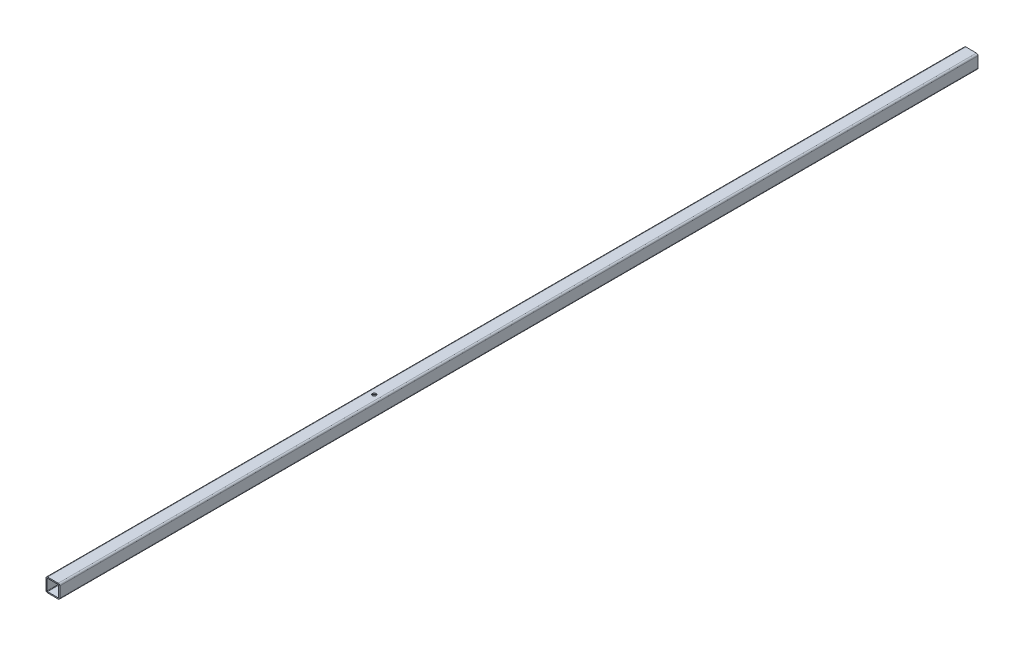
from build123d import *

# Parameters (mm, degrees)
EXTRUDE1_DEPTH     = 1000
SKETCH2_R          = 2
CUT_EXTRUDE1_DEPTH = 2
SKETCH3_R          = 2
CUT_EXTRUDE2_DEPTH = 2


with BuildPart() as part:
    # Sketch1 → Extrude1 (new body)
    with BuildSketch(Plane.XY):
        with BuildLine():
            Line((-5.8, 7.5), (5.8, 7.5))
            ThreePointArc((5.8, 7.5), (7.002081528, 7.002081528), (7.5, 5.8))
            Line((7.5, 5.8), (7.5, -5.8))
            ThreePointArc((7.5, -5.8), (7.002081528, -7.002081528), (5.8, -7.5))
            Line((5.8, -7.5), (-5.8, -7.5))
            ThreePointArc((-5.8, -7.5), (-7.002081528, -7.002081528), (-7.5, -5.8))
            Line((-7.5, -5.8), (-7.5, 5.8))
            ThreePointArc((-7.5, 5.8), (-7.002081528, 7.002081528), (-5.8, 7.5))
        make_face()
        with BuildLine():
            Line((-6.3, 5.8), (-6.3, -5.8))
            ThreePointArc((-6.3, -5.8), (-6.153553391, -6.153553391), (-5.8, -6.3))
            Line((-5.8, -6.3), (5.8, -6.3))
            ThreePointArc((5.8, -6.3), (6.153553391, -6.153553391), (6.3, -5.8))
            Line((6.3, -5.8), (6.3, 5.8))
            ThreePointArc((6.3, 5.8), (6.153553391, 6.153553391), (5.8, 6.3))
            Line((5.8, 6.3), (-5.8, 6.3))
            ThreePointArc((-5.8, 6.3), (-6.153553391, 6.153553391), (-6.3, 5.8))
        make_face(mode=Mode.SUBTRACT)
    extrude(amount=EXTRUDE1_DEPTH)

    # Sketch2 → Cut-Extrude1 (cut)
    with BuildSketch(Plane.ZY.offset(7.5)):
        with Locations((697, 0)):
            Circle(SKETCH2_R)
    extrude(amount=-CUT_EXTRUDE1_DEPTH, mode=Mode.SUBTRACT)

    # Sketch3 → Cut-Extrude2 (cut)
    with BuildSketch(Plane(origin=(0, 7.5, 0), x_dir=(-1, 0, 0), z_dir=(0, 1, 0))):
        with Locations((0, 650)):
            Circle(SKETCH3_R)
    extrude(amount=-CUT_EXTRUDE2_DEPTH, mode=Mode.SUBTRACT)


solid = part.part
